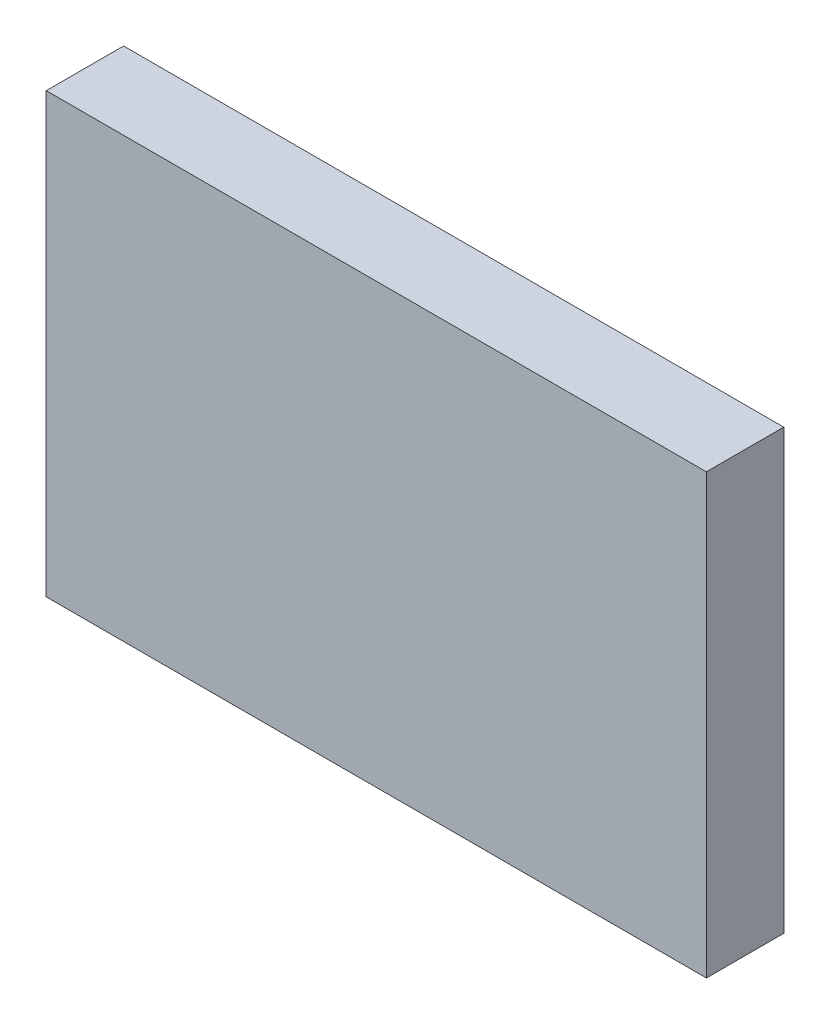
from build123d import *

# Parameters (mm, degrees)
SKETCH1_W           = 162.56
SKETCH1_H           = 107.95
BOSS_EXTRUDE1_DEPTH = 19.05


with BuildPart() as part:
    # Sketch1 → Boss-Extrude1 (new body)
    with BuildSketch(Plane.XY):
        with Locations((-81.28, 53.975)):
            Rectangle(SKETCH1_W, SKETCH1_H)
    extrude(amount=BOSS_EXTRUDE1_DEPTH)


solid = part.part
